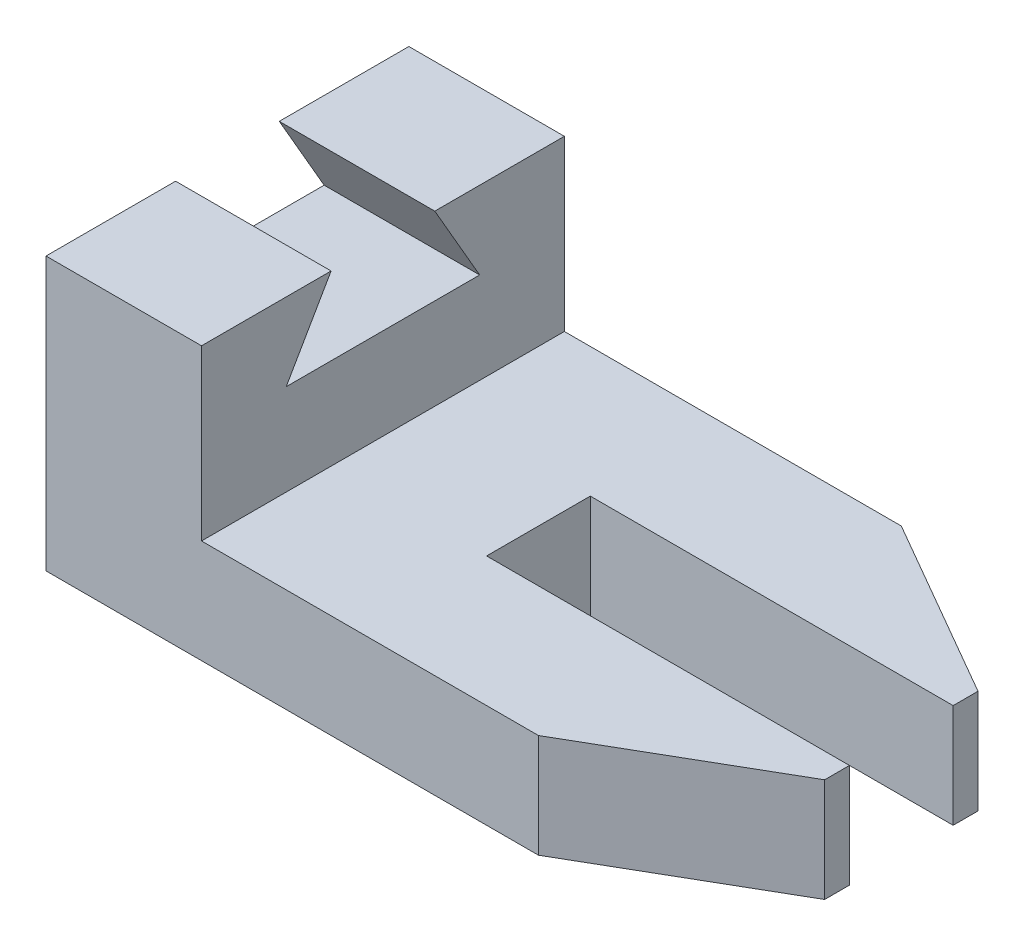
from build123d import *

# Parameters (mm, degrees)
SALIENTE_EXTRUIR4_DEPTH = 20
SALIENTE_EXTRUIR5_DEPTH = 30


with BuildPart() as part:
    # Croquis2 → Saliente-Extruir4 (new body)
    with BuildSketch(Plane(origin=(0, 0, 0), x_dir=(1, 0, 0), z_dir=(0, 1, 0))):
        Polygon((130, 20.207259422), (130, 24.997259422), (60, 24.997259422), (60, 44.997259422), (130, 44.997259422), (130, 49.792740578), (95, 70), (0, 70), (0, 0), (95, 0), align=None)
    extrude(amount=SALIENTE_EXTRUIR4_DEPTH)

    # Croquis4 → Saliente-Extruir5 (add)
    with BuildSketch(Plane.ZY):
        Polygon((0, 20), (0, 52.609160269), (-25, 52.609160269), (-16.339745962, 37.609160269), (-35, 37.609160269), (-35, 20), align=None)
    saliente_extruir5 = extrude(amount=-SALIENTE_EXTRUIR5_DEPTH)

    # Simetría1: Saliente-Extruir5 across plane
    add(saliente_extruir5.mirror(Plane(origin=(0, 0, -35), x_dir=(1, 0, 0), z_dir=(0, 0, -1))))


solid = part.part
